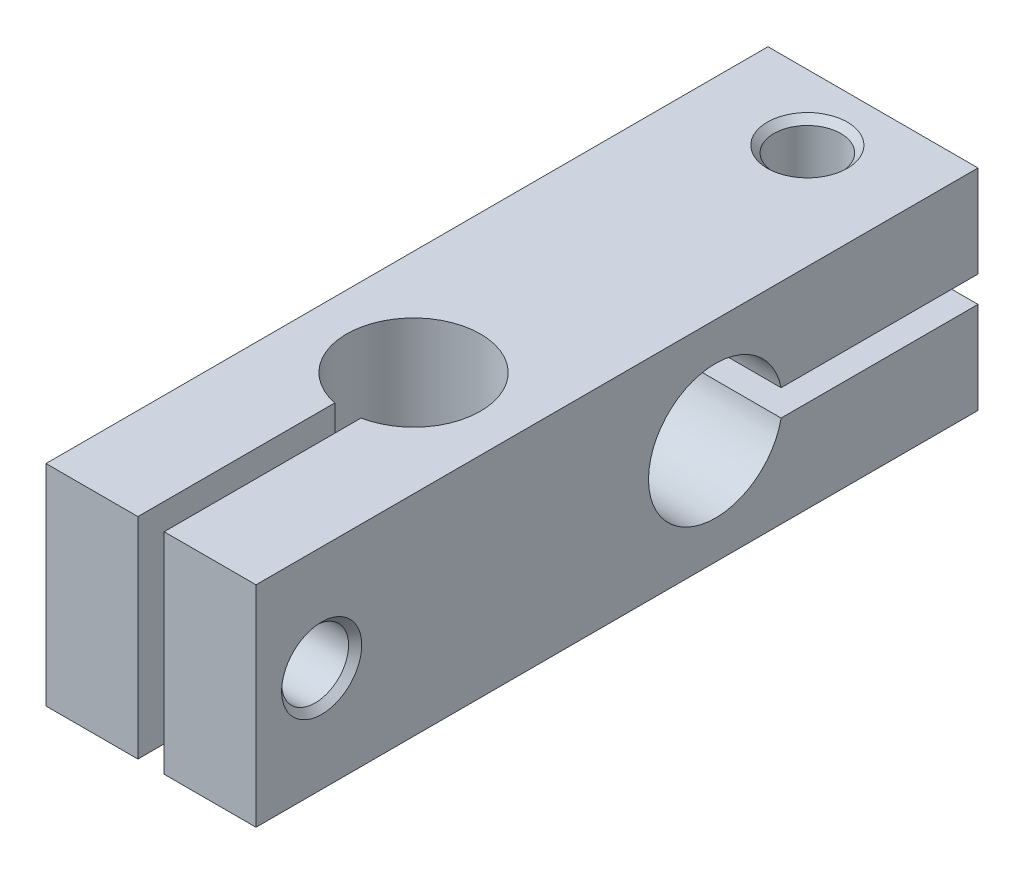
from build123d import *

# Parameters (mm, degrees)
SKETCH1_W                                 = 16
SKETCH1_H                                 = 16
BASE_DEPTH                                = 55
SKETCH2_W                                 = 2
SKETCH2_H                                 = 16
RODSLOT_DEPTH                             = 17
F_5_1_5_1_FREE_HOLE_FOR_SCREW_D           = 5.1
F_5_1_5_1_FREE_HOLE_FOR_SCREW_DEPTH       = 7.5
F_5_1_5_1_FREE_HOLE_FOR_SCREW_CSINK_D     = 6.1
F_5_1_5_1_FREE_HOLE_FOR_SCREW_CSINK_ANGLE = 90
F_5_1_5_1_FREE_HOLE_FOR_SCREW_TIP         = 1.056244584
M5X0_8_TAPPED_HOLE_FOR_ROD_SCREW_D        = 4.2
M5X0_8_TAPPED_HOLE_FOR_ROD_SCREW_DEPTH    = 7.6381927
M5X0_8_TAPPED_HOLE_FOR_ROD_SCREW_TIP      = 1.2618073
F_10_2_10_2_ROD_HOLE_D                    = 10.2
SKETCH13_W                                = 20
SKETCH13_H                                = 2
ROD2SLOT_DEPTH                            = 17
F_10_2_10_2_ROD2_HOLE_D                   = 10.2
F_5_1_5_1_DIAMETER_HOLE1_D                = 5.1
F_5_1_5_1_DIAMETER_HOLE1_DEPTH            = 7.5
F_5_1_5_1_DIAMETER_HOLE1_CSINK_D          = 6.1
F_5_1_5_1_DIAMETER_HOLE1_CSINK_ANGLE      = 90
F_5_1_5_1_DIAMETER_HOLE1_TIP              = 1.056244584
M5X0_8_TAPPED_HOLE1_D                     = 4.2
M5X0_8_TAPPED_HOLE1_DEPTH                 = 7.6381927
M5X0_8_TAPPED_HOLE1_TIP                   = 1.2618073


with BuildPart() as part:
    # Sketch1 → Base (new body)
    with BuildSketch(Plane.XY):
        Rectangle(SKETCH1_W, SKETCH1_H)
    extrude(amount=BASE_DEPTH)

    # Sketch2 → RodSlot (cut, through all)
    with BuildSketch(Plane(origin=(0, 8, 0), x_dir=(1, 0, 0), z_dir=(0, 1, 0))):
        with Locations((0, -47)):
            Rectangle(SKETCH2_W, SKETCH2_H)
    extrude(amount=-RODSLOT_DEPTH, mode=Mode.SUBTRACT)

    # Ø5.1 (5.1) free hole for screw
    with Locations(Plane(origin=(8, 0, 0), x_dir=(0, 0, -1), z_dir=(1, 0, 0))):
        with Locations((-50, 0)):
            CounterSinkHole(F_5_1_5_1_FREE_HOLE_FOR_SCREW_D / 2, F_5_1_5_1_FREE_HOLE_FOR_SCREW_CSINK_D / 2, depth=F_5_1_5_1_FREE_HOLE_FOR_SCREW_DEPTH, counter_sink_angle=F_5_1_5_1_FREE_HOLE_FOR_SCREW_CSINK_ANGLE)
            with Locations((0, 0, -(F_5_1_5_1_FREE_HOLE_FOR_SCREW_DEPTH + F_5_1_5_1_FREE_HOLE_FOR_SCREW_TIP / 2))):  # 135° drill point
                Cone(0, F_5_1_5_1_FREE_HOLE_FOR_SCREW_D / 2, F_5_1_5_1_FREE_HOLE_FOR_SCREW_TIP, mode=Mode.SUBTRACT)

    # M5x0.8 Tapped Hole for rod screw
    with Locations(Plane.ZY.offset(8)):
        with Locations((50, 0)):
            Hole(M5X0_8_TAPPED_HOLE_FOR_ROD_SCREW_D / 2, depth=M5X0_8_TAPPED_HOLE_FOR_ROD_SCREW_DEPTH)
            with Locations((0, 0, -(M5X0_8_TAPPED_HOLE_FOR_ROD_SCREW_DEPTH + M5X0_8_TAPPED_HOLE_FOR_ROD_SCREW_TIP / 2))):  # 118° drill point
                Cone(0, M5X0_8_TAPPED_HOLE_FOR_ROD_SCREW_D / 2, M5X0_8_TAPPED_HOLE_FOR_ROD_SCREW_TIP, mode=Mode.SUBTRACT)

    # Ø10.2 (10.2) Rod Hole (through all)
    with Locations(Plane(origin=(0, 8, 0), x_dir=(1, 0, 0), z_dir=(0, 1, 0))):
        with Locations((0, -35)):
            Hole(F_10_2_10_2_ROD_HOLE_D / 2)

    # Sketch13 → Rod2Slot (cut, through all)
    with BuildSketch(Plane.ZY.offset(8)):
        with Locations((10, 0)):
            Rectangle(SKETCH13_W, SKETCH13_H)
    extrude(amount=-ROD2SLOT_DEPTH, mode=Mode.SUBTRACT)

    # Ø10.2 (10.2) Rod2 Hole (through all)
    with Locations(Plane(origin=(-8, 0, 0), x_dir=(0, 1, 0), z_dir=(-1, 0, 0))):
        with Locations((0, -20)):
            Hole(F_10_2_10_2_ROD2_HOLE_D / 2)

    # Ø5.1 (5.1) Diameter Hole1
    with Locations(Plane(origin=(0, 8, 0), x_dir=(0, 0, -1), z_dir=(0, 1, 0))):
        with Locations((-5, 0)):
            CounterSinkHole(F_5_1_5_1_DIAMETER_HOLE1_D / 2, F_5_1_5_1_DIAMETER_HOLE1_CSINK_D / 2, depth=F_5_1_5_1_DIAMETER_HOLE1_DEPTH, counter_sink_angle=F_5_1_5_1_DIAMETER_HOLE1_CSINK_ANGLE)
            with Locations((0, 0, -(F_5_1_5_1_DIAMETER_HOLE1_DEPTH + F_5_1_5_1_DIAMETER_HOLE1_TIP / 2))):  # 135° drill point
                Cone(0, F_5_1_5_1_DIAMETER_HOLE1_D / 2, F_5_1_5_1_DIAMETER_HOLE1_TIP, mode=Mode.SUBTRACT)

    # M5x0.8 Tapped Hole1
    with Locations(Plane(origin=(0, -8, 0), x_dir=(-1, 0, 0), z_dir=(0, -1, 0))):
        with Locations((0, -5)):
            Hole(M5X0_8_TAPPED_HOLE1_D / 2, depth=M5X0_8_TAPPED_HOLE1_DEPTH)
            with Locations((0, 0, -(M5X0_8_TAPPED_HOLE1_DEPTH + M5X0_8_TAPPED_HOLE1_TIP / 2))):  # 118° drill point
                Cone(0, M5X0_8_TAPPED_HOLE1_D / 2, M5X0_8_TAPPED_HOLE1_TIP, mode=Mode.SUBTRACT)


solid = part.part
